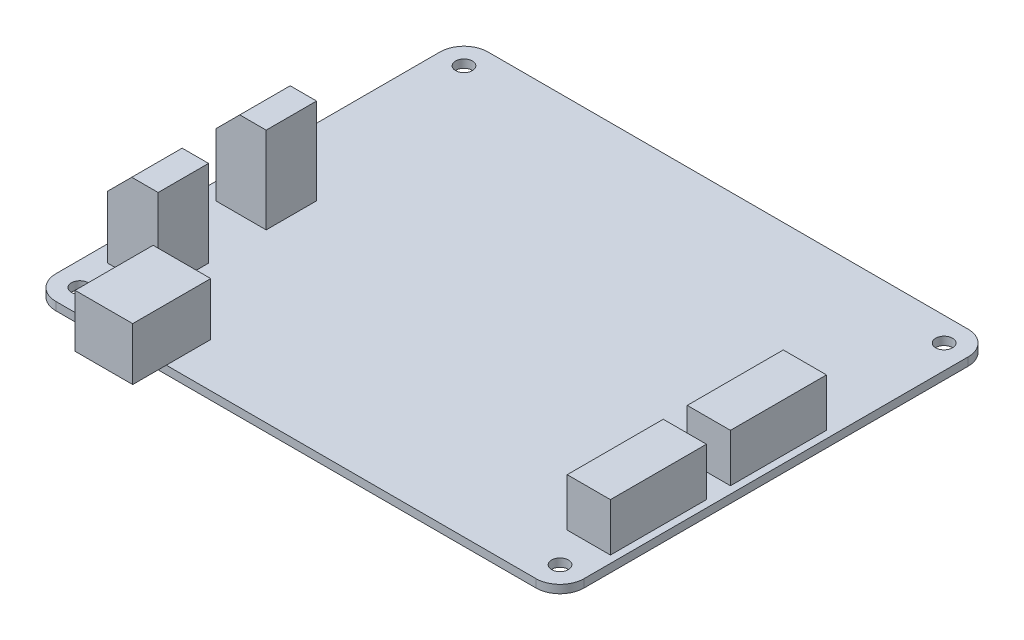
from build123d import *

# Parameters (mm, degrees)
SKETCH1_W                      = 110
SKETCH1_H                      = 90
BOSS_EXTRUDE1_DEPTH            = 1.7
CUT_EXTRUDE1_REACH             = 3.7
SKETCH2_R                      = 1.75
CUT_EXTRUDE1_DIRECTION_2_DEPTH = 1
FILLET1_R                      = 5
SKETCH3_W                      = 10.5
SKETCH3_H                      = 10.5
BOSS_EXTRUDE2_DEPTH            = 18
CHAMFER1_SIZE                  = 5
SKETCH4_W                      = 12
SKETCH4_H                      = 16.25
BOSS_EXTRUDE3_DEPTH            = 11
SKETCH5_W                      = 9
SKETCH5_H                      = 20
BOSS_EXTRUDE4_DEPTH            = 10


with BuildPart() as part:
    # Sketch1 → Boss-Extrude1 (new body)
    with BuildSketch(Plane(origin=(0, 0, 0), x_dir=(1, 0, 0), z_dir=(0, 1, 0))):
        Rectangle(SKETCH1_W, SKETCH1_H)
    extrude(amount=BOSS_EXTRUDE1_DEPTH)

    # Sketch2 → Cut-Extrude1 (cut, up to next)
    with BuildSketch(Plane(origin=(0, 1.7, 0), x_dir=(1, 0, 0), z_dir=(0, 1, 0)), mode=Mode.PRIVATE) as cut_extrude1_sk1:
        with Locations((-50, 40)):
            Circle(SKETCH2_R)
    cut_extrude1_tool1 = extrude(cut_extrude1_sk1.sketch, amount=-CUT_EXTRUDE1_REACH, mode=Mode.PRIVATE) & part.part
    add(cut_extrude1_tool1.solids().sort_by_distance((-50, 1.7, -40))[0], mode=Mode.SUBTRACT)
    # Sketch2 → Cut-Extrude1 (cut, up to next)
    with BuildSketch(Plane(origin=(0, 1.7, 0), x_dir=(1, 0, 0), z_dir=(0, 1, 0)), mode=Mode.PRIVATE) as cut_extrude1_sk2:
        with Locations((-50, -40)):
            Circle(SKETCH2_R)
    cut_extrude1_tool2 = extrude(cut_extrude1_sk2.sketch, amount=-CUT_EXTRUDE1_REACH, mode=Mode.PRIVATE) & part.part
    add(cut_extrude1_tool2.solids().sort_by_distance((-50, 1.7, 40))[0], mode=Mode.SUBTRACT)
    # Sketch2 → Cut-Extrude1 (cut, up to next)
    with BuildSketch(Plane(origin=(0, 1.7, 0), x_dir=(1, 0, 0), z_dir=(0, 1, 0)), mode=Mode.PRIVATE) as cut_extrude1_sk3:
        with Locations((50, -40)):
            Circle(SKETCH2_R)
    cut_extrude1_tool3 = extrude(cut_extrude1_sk3.sketch, amount=-CUT_EXTRUDE1_REACH, mode=Mode.PRIVATE) & part.part
    add(cut_extrude1_tool3.solids().sort_by_distance((50, 1.7, 40))[0], mode=Mode.SUBTRACT)
    # Sketch2 → Cut-Extrude1 (cut, up to next)
    with BuildSketch(Plane(origin=(0, 1.7, 0), x_dir=(1, 0, 0), z_dir=(0, 1, 0)), mode=Mode.PRIVATE) as cut_extrude1_sk4:
        with Locations((50, 40)):
            Circle(SKETCH2_R)
    cut_extrude1_tool4 = extrude(cut_extrude1_sk4.sketch, amount=-CUT_EXTRUDE1_REACH, mode=Mode.PRIVATE) & part.part
    add(cut_extrude1_tool4.solids().sort_by_distance((50, 1.7, -40))[0], mode=Mode.SUBTRACT)

    # Sketch2 → Cut-Extrude1 direction 2 (cut)
    with BuildSketch(Plane(origin=(0, 1.7, 0), x_dir=(1, 0, 0), z_dir=(0, 1, 0))):
        with Locations((-50, 40)):
            Circle(SKETCH2_R)
        with Locations((-50, -40)):
            Circle(SKETCH2_R)
        with Locations((50, -40)):
            Circle(SKETCH2_R)
        with Locations((50, 40)):
            Circle(SKETCH2_R)
    extrude(amount=CUT_EXTRUDE1_DIRECTION_2_DEPTH, mode=Mode.SUBTRACT)

    # Fillet1
    fillet1_edges = [part.edges().sort_by_distance(p)[0] for p in [
        (55, 0.85, 45),
        (-55, 0.85, 45),
        (-55, 0.85, -45),
        (55, 0.85, -45),
    ]]
    fillet(fillet1_edges, radius=FILLET1_R)

    # Sketch3 → Boss-Extrude2 (add)
    with BuildSketch(Plane(origin=(0, 1.7, 0), x_dir=(1, 0, 0), z_dir=(0, 1, 0))):
        with Locations((-46.25, -27.45)):
            Rectangle(SKETCH3_W, SKETCH3_H)
        with Locations((-46.25, -4.95)):
            Rectangle(SKETCH3_W, SKETCH3_H)
    extrude(amount=BOSS_EXTRUDE2_DEPTH)

    # Chamfer1
    chamfer1_edges = [part.edges().sort_by_distance(p)[0] for p in [
        (-51.5, 19.7, 27.45),
        (-51.5, 19.7, 4.95),
    ]]
    chamfer(chamfer1_edges, length=CHAMFER1_SIZE)

    # Sketch4 → Boss-Extrude3 (add)
    with BuildSketch(Plane(origin=(0, 1.7, 0), x_dir=(1, 0, 0), z_dir=(0, 1, 0))):
        with Locations((-33, -43.875)):
            Rectangle(SKETCH4_W, SKETCH4_H)
    extrude(amount=BOSS_EXTRUDE3_DEPTH)

    # Sketch5 → Boss-Extrude4 (add)
    with BuildSketch(Plane(origin=(0, 1.7, 0), x_dir=(1, 0, 0), z_dir=(0, 1, 0))):
        with Locations((49, -23)):
            Rectangle(SKETCH5_W, SKETCH5_H)
        with Locations((49, 2)):
            Rectangle(SKETCH5_W, SKETCH5_H)
    extrude(amount=BOSS_EXTRUDE4_DEPTH)


solid = part.part
